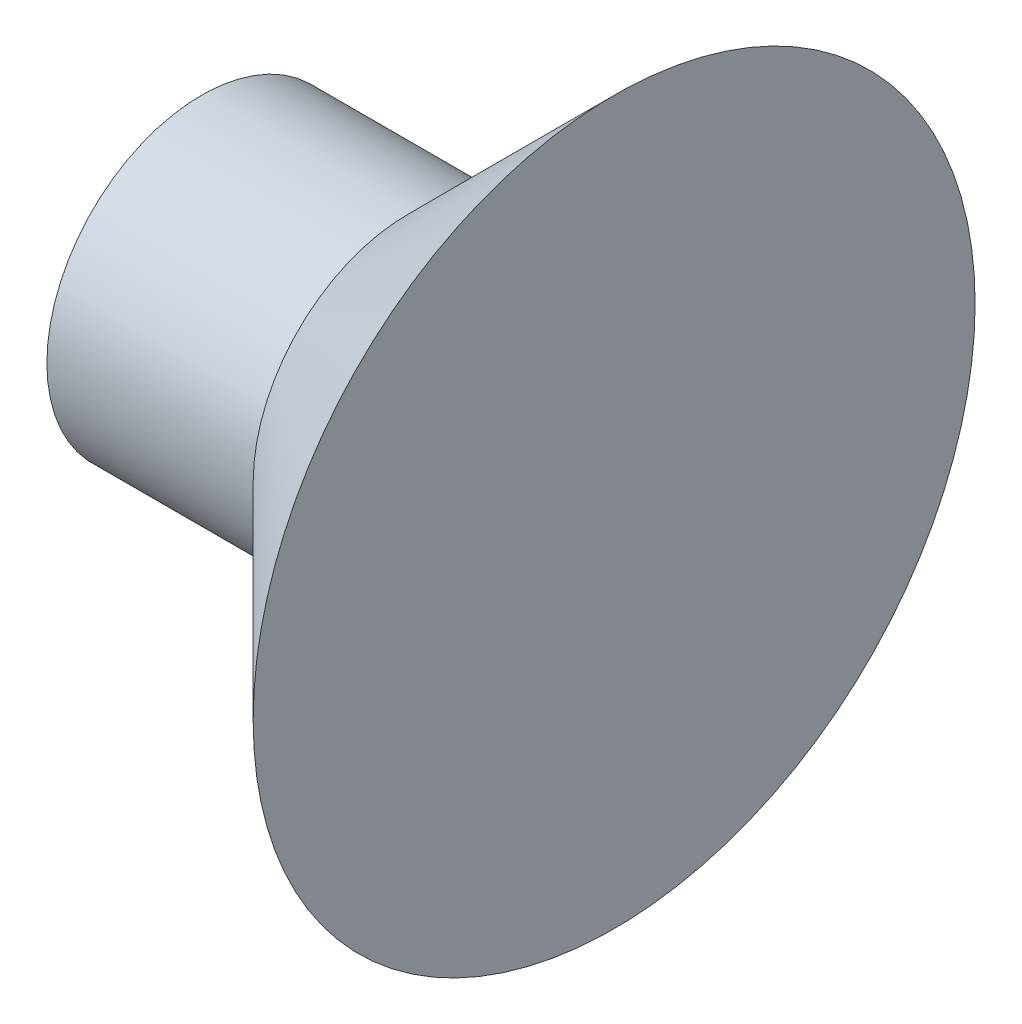
from build123d import *


with BuildPart() as part:
    # Esquisse1 → Révolution1 (revolve)
    with BuildSketch(Plane.XY, mode=Mode.PRIVATE) as r_volution1_sk:
        Polygon((0, 0), (-4, 0), (-4, 1.5), (-2, 1.5), (0, 3.5), align=None)
    revolve(r_volution1_sk.sketch.rotate(Axis((0, 0, 0), (1, 0, 0)), 90), axis=Axis((0, 0, 0), (1, 0, 0)))  # turned: the seam where the file's is


solid = part.part
